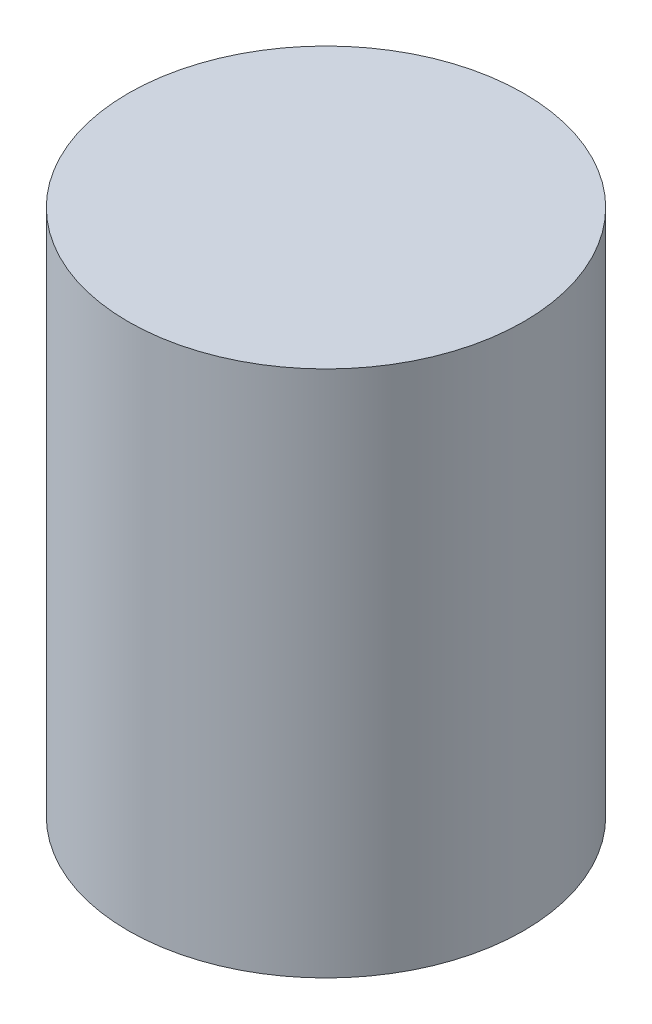
from build123d import *

# Parameters (mm, degrees)
SKETCH_1_R      = 30
EXTRUDE_1_DEPTH = 80


with BuildPart() as part:
    # 草图1 → 凸台-拉伸1 (new body)
    with BuildSketch(Plane(origin=(0, 0, 0), x_dir=(1, 0, 0), z_dir=(0, 1, 0))):
        Circle(SKETCH_1_R)
    extrude(amount=EXTRUDE_1_DEPTH)


solid = part.part
